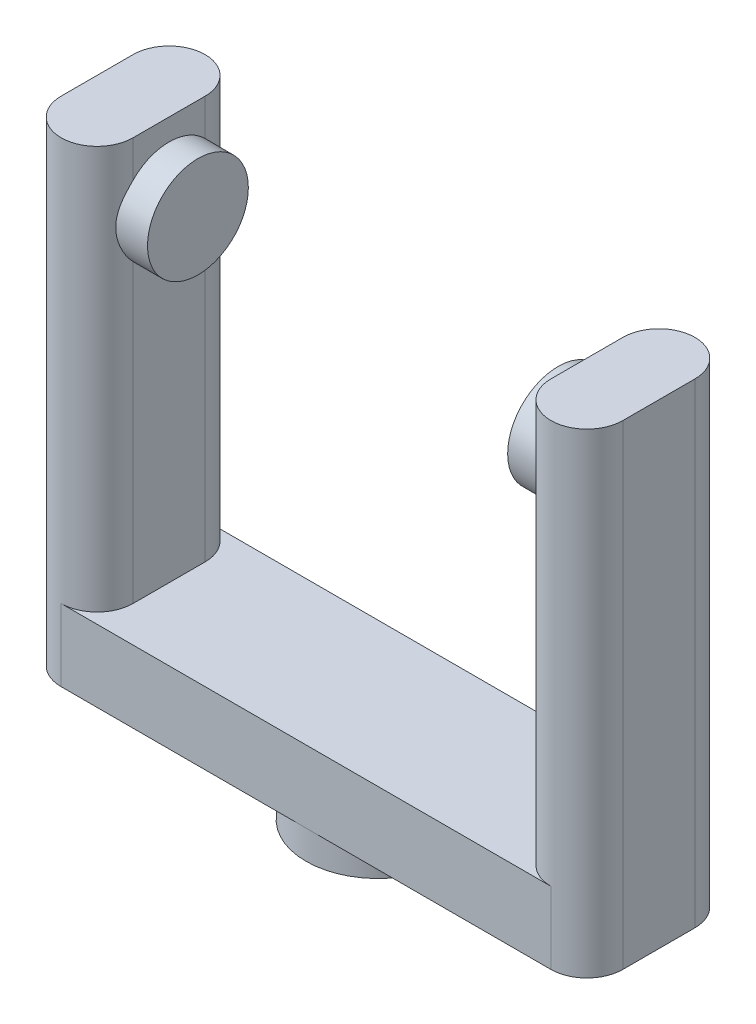
from build123d import *

# Parameters (mm, degrees)
BOSS_EXTRU_2_DEPTH      = 5
BOSS_EXTRU_3_DEPTH      = 28
ESQUISSE3_R             = 3.5
BOSS_EXTRU_5_DEPTH      = 2
BOSS_EXTRU_5_DEPTH_BACK = 1
BOSS_EXTRU_7_DEPTH      = 7
ESQUISSE4_R             = 3.5
BOSS_EXTRU_8_DEPTH      = 2
BOSS_EXTRU_8_DEPTH_BACK = 1


with BuildPart() as part:
    # Esquisse1 → Boss.-Extru.2 (new body)
    with BuildSketch(Plane(origin=(0, 0, 0), x_dir=(1, 0, 0), z_dir=(0, 1, 0))):
        with BuildLine():
            Line((-17, -5), (17, -5))
            ThreePointArc((17, -5), (18.767766953, -4.267766953), (19.5, -2.5))
            Line((19.5, -2.5), (19.5, 2.5))
            ThreePointArc((19.5, 2.5), (18.767766953, 4.267766953), (17, 5))
            Line((17, 5), (-17, 5))
            ThreePointArc((-17, 5), (-18.767766953, 4.267766953), (-19.5, 2.5))
            Line((-19.5, 2.5), (-19.5, -2.5))
            ThreePointArc((-19.5, -2.5), (-18.767766953, -4.267766953), (-17, -5))
        make_face()
    extrude(amount=-BOSS_EXTRU_2_DEPTH)

    # Esquisse1_6 → Boss.-Extru.3 (add)
    with BuildSketch(Plane(origin=(0, 0, 0), x_dir=(1, 0, 0), z_dir=(0, 1, 0))):
        with BuildLine():
            ThreePointArc((-19.5, -2.5), (-17, -5), (-14.5, -2.5))
            Line((-14.5, -2.5), (-14.5, 2.5))
            ThreePointArc((-14.5, 2.5), (-17, 5), (-19.5, 2.5))
            Line((-19.5, 2.5), (-19.5, -2.5))
        make_face()
        with BuildLine():
            ThreePointArc((14.5, -2.5), (17, -5), (19.5, -2.5))
            Line((19.5, -2.5), (19.5, 2.5))
            ThreePointArc((19.5, 2.5), (17, 5), (14.5, 2.5))
            Line((14.5, 2.5), (14.5, -2.5))
        make_face()
    extrude(amount=BOSS_EXTRU_3_DEPTH)

    # Esquisse3 → Boss.-Extru.5 (add, two sides)
    with BuildSketch(Plane(origin=(-14.5, 0, 0), x_dir=(0, 0, -1), z_dir=(1, 0, 0))) as boss_extru_5_sk:
        with Locations((0, 23)):
            Circle(ESQUISSE3_R)
    extrude(amount=BOSS_EXTRU_5_DEPTH)
    extrude(boss_extru_5_sk.sketch, amount=-BOSS_EXTRU_5_DEPTH_BACK)

    # Esquisse1_9 → Boss.-Extru.7 (add)
    with BuildSketch(Plane(origin=(0, 0, 0), x_dir=(1, 0, 0), z_dir=(0, 1, 0))):
        with BuildLine():
            ThreePointArc((-5, 0), (-3.535533906, -3.535533906), (0, -5))
            ThreePointArc((0, -5), (3.535533906, -3.535533906), (5, 0))
            Line((5, 0), (3.5, 0))
            ThreePointArc((3.5, 0), (0, -3.5), (-3.5, 0))
            Line((-3.5, 0), (-5, 0))
        make_face()
        with BuildLine():
            Line((3.5, 0), (5, 0))
            ThreePointArc((5, 0), (3.535533906, 3.535533906), (0, 5))
            ThreePointArc((0, 5), (-3.535533906, 3.535533906), (-5, 0))
            Line((-5, 0), (-3.5, 0))
            ThreePointArc((-3.5, 0), (0, 3.5), (3.5, 0))
        make_face()
    extrude(amount=-BOSS_EXTRU_7_DEPTH)

    # Esquisse4 → Boss.-Extru.8 (add, two sides)
    with BuildSketch(Plane.ZY.offset(-14.5)) as boss_extru_8_sk:
        with Locations((0, 23)):
            Circle(ESQUISSE4_R)
    extrude(amount=BOSS_EXTRU_8_DEPTH)
    extrude(boss_extru_8_sk.sketch, amount=-BOSS_EXTRU_8_DEPTH_BACK)


solid = part.part
